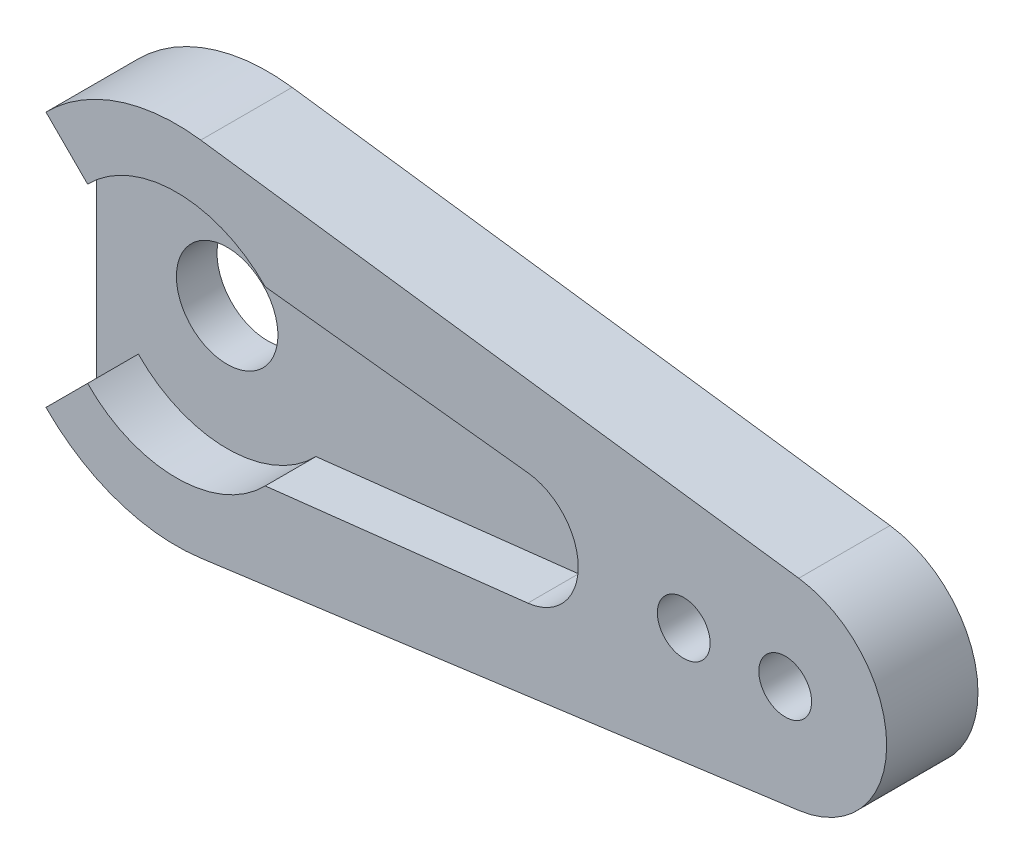
from build123d import *

# Parameters (mm, degrees)
MAIN_DEPTH            = 2.5
ESQUISSE2_R           = 2.5
ORIGINALBRACKET_DEPTH = 2
ESQUISSE3_R           = 1.3
FIXINGHOLE_DEPTH      = 5.5


with BuildPart() as part:
    # Esquisse1 → Main (new body)
    with BuildSketch(Plane.XY):
        with BuildLine():
            Line((-4.375785644, 4.25), (-6.426543071, 6.300757427))
            ThreePointArc((-6.426543071, 6.300757427), (-2.922982421, 8.512119229), (1.2, 8.919641248))
            Line((1.2, 8.919641248), (30.666666667, 4.955356249))
            ThreePointArc((30.666666667, 4.955356249), (35, 0), (30.666666667, -4.955356249))
            Line((30.666666667, -4.955356249), (1.2, -8.919641248))
            ThreePointArc((1.2, -8.919641248), (-2.922982421, -8.512119229), (-6.426543071, -6.300757427))
            Line((-6.426543071, -6.300757427), (-4.375785644, -4.25))
            ThreePointArc((-4.375785644, -4.25), (0, -6.1), (4.375785644, -4.25))
            Line((4.375785644, -4.25), (17.31559729, -2.78215714))
            ThreePointArc((17.31559729, -2.78215714), (19.8, 0), (17.31559729, 2.78215714))
            Line((17.31559729, 2.78215714), (4.375785644, 4.25))
            ThreePointArc((4.375785644, 4.25), (0, 6.1), (-4.375785644, 4.25))
        make_face()
    extrude(amount=MAIN_DEPTH)

    # Esquisse2 → OriginalBracket (add)
    with BuildSketch(Plane(origin=(0, 0, 0), x_dir=(-1, 0, 0), z_dir=(0, 0, -1))):
        with BuildLine():
            Line((-1.2, -8.919641248), (-30.666666667, -4.955356249))
            ThreePointArc((-30.666666667, -4.955356249), (-35, 0), (-30.666666667, 4.955356249))
            Line((-30.666666667, 4.955356249), (-1.2, 8.919641248))
            ThreePointArc((-1.2, 8.919641248), (2.922982421, 8.512119229), (6.426543071, 6.300757427))
            Line((6.426543071, 6.300757427), (6.426543071, -6.300757427))
            ThreePointArc((6.426543071, -6.300757427), (2.922982421, -8.512119229), (-1.2, -8.919641248))
        make_face()
        Circle(ESQUISSE2_R, mode=Mode.SUBTRACT)
    extrude(amount=ORIGINALBRACKET_DEPTH)

    # Esquisse3 → FixingHole (cut, through all)
    with BuildSketch(Plane.XY.offset(2.5)):
        with Locations((30, 0)):
            Circle(ESQUISSE3_R)
        with Locations((25, 0)):
            Circle(ESQUISSE3_R)
    extrude(amount=-FIXINGHOLE_DEPTH, mode=Mode.SUBTRACT)


solid = part.part
